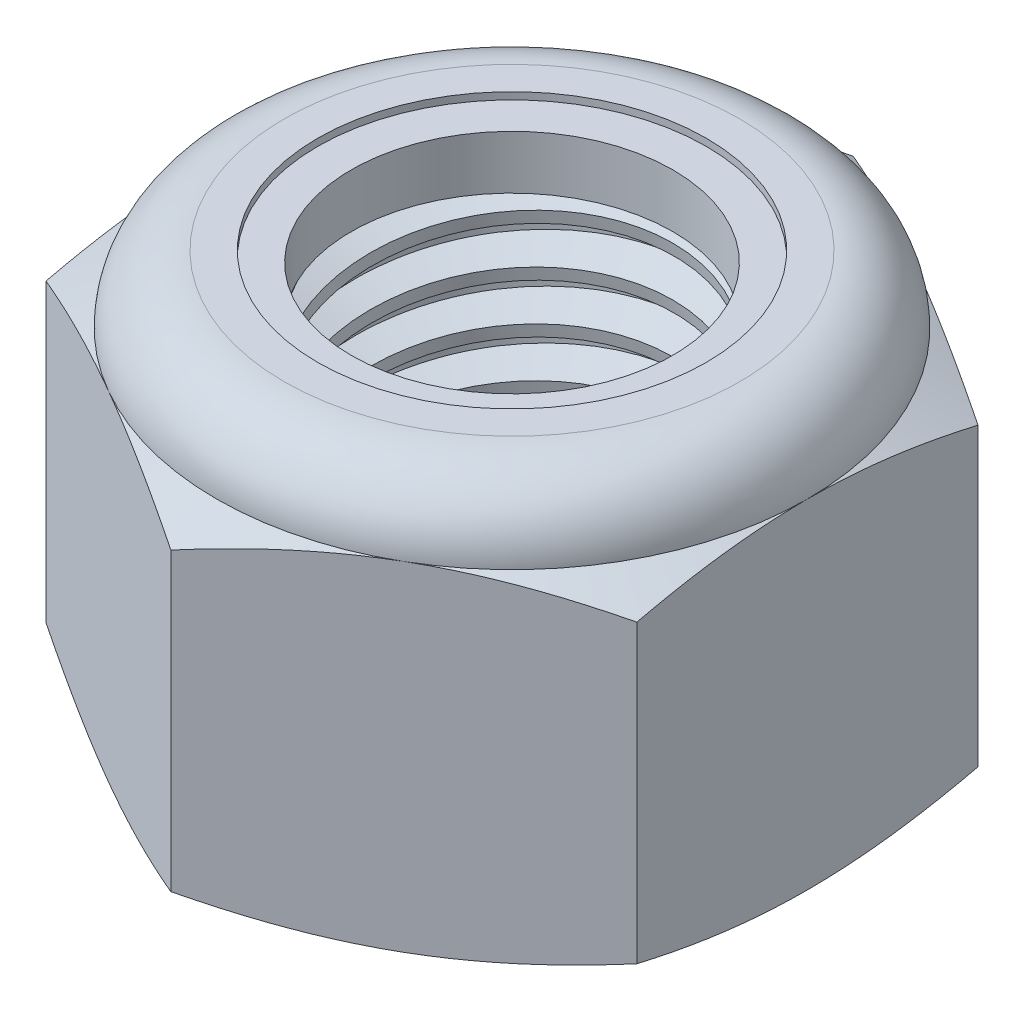
from build123d import *

# Parameters (mm, degrees)
EXTRUDE1_DEPTH       = 8.73125
SKETCH2_W            = 3.9624
SKETCH2_H            = 8.73125
LPATTERN1_COUNT      = 8
LPATTERN1_PITCH      = 1.058333333
LPATTERN1_COUNT_DIR2 = 2
LPATTERN1_PITCH_DIR2 = 1.058333333


with BuildPart() as part:
    # Sketch1 → Extrude1 (new body)
    with BuildSketch(Plane(origin=(0, 0, 0), x_dir=(1, 0, 0), z_dir=(0, 1, 0))):
        Polygon((0, 7.332348419), (-6.35, 3.666174209), (-6.35, -3.666174209), (0, -7.332348419), (6.35, -3.666174209), (6.35, 3.666174209), align=None)
    extrude(amount=EXTRUDE1_DEPTH)

    # Sketch4 → Cut-Revolve2 (revolve, cut)
    with BuildSketch(Plane(origin=(0, 0, 0), x_dir=(0, 0, -1), z_dir=(1, 0, 0))):
        Polygon((0, 8.73125), (3.9624, 8.73125), (3.4558921, 8.495061487), (3.4558921, 0.236188513), (3.9624, 0), (0, 0), align=None)
    revolve(axis=Axis((0, 8.73125, 0), (0, 1, 0)), mode=Mode.SUBTRACT)


with BuildPart() as body_2:
    # Sketch2 → Revolve1 (revolve)
    with BuildSketch(Plane(origin=(0, 0, 0), x_dir=(0, 0, -1), z_dir=(1, 0, 0))):
        with Locations((1.9812, 4.365625)):
            Rectangle(SKETCH2_W, SKETCH2_H)
    revolve(axis=Axis((0, -3.9624, 0), (0, 1, 0)))

    # Sketch3 → Cut-Revolve1 (revolve, cut)
    with BuildSketch(Plane(origin=(0, 0, 0), x_dir=(0, 0, -1), z_dir=(1, 0, 0))):
        Polygon((3.979911688, 8.600122482), (4.102493502, 7.682229859), (3.490915476, 7.934220821), (3.4558921, 8.196475856), align=None)
    cut_revolve1 = revolve(axis=Axis((0, 8.73125, 0.150876649), (0, -0.9912001327823777, -0.1323718126044843)), mode=Mode.SUBTRACT)

    # LPattern1: Cut-Revolve1 8 × 2
    with Locations(*[Vector(0, -1, 0) * (i * LPATTERN1_PITCH) + Vector(0, 1, 0) * (j * LPATTERN1_PITCH_DIR2) for i in range(LPATTERN1_COUNT) for j in range(LPATTERN1_COUNT_DIR2) if (i, j) != (0, 0)]):
        add(cut_revolve1, mode=Mode.SUBTRACT)


with BuildPart() as part_1:
    add(part.part)

    # Combine1: cut body 2
    add(body_2.part, mode=Mode.SUBTRACT)

    # Sketch5 → Cut-Revolve3 (revolve, cut)
    with BuildSketch(Plane(origin=(0, 0, 0), x_dir=(0, 0, -1), z_dir=(1, 0, 0))):
        with BuildLine():
            Line((0, 0), (6.35, 0))
            Line((6.35, 0), (7.332348419, 0.458076591))
            Line((7.332348419, 0.458076591), (7.332348419, 6.817965076))
            Line((7.332348419, 6.817965076), (6.35, 7.276041667))
            ThreePointArc((6.35, 7.276041667), (5.923779347, 8.305029347), (4.894791667, 8.73125))
            Line((4.894791667, 8.73125), (4.894791667, 10.00125))
            Line((4.894791667, 10.00125), (8.602348419, 10.00125))
            Line((8.602348419, 10.00125), (8.602348419, -1.27))
            Line((8.602348419, -1.27), (0, -1.27))
            Line((0, -1.27), (0, 0))
        make_face()
    revolve(axis=Axis((0, 0, 0), (0, 1, 0)), mode=Mode.SUBTRACT)

    # Sketch6 → Cut-Revolve4 (revolve, cut)
    with BuildSketch(Plane(origin=(0, 0, 0), x_dir=(0, 0, -1), z_dir=(1, 0, 0))):
        with BuildLine():
            Line((0, 7.276041667), (6.1976, 7.276041667))
            ThreePointArc((6.1976, 7.276041667), (5.816016274, 8.197266274), (4.894791667, 8.57885))
            Line((4.894791667, 8.57885), (4.175341883, 8.57885))
            Line((4.175341883, 8.57885), (4.175341883, 10.00125))
            Line((4.175341883, 10.00125), (0, 10.00125))
            Line((0, 10.00125), (0, 7.276041667))
        make_face()
    revolve(axis=Axis((0, 10.00125, 0), (0, 1, 0)), mode=Mode.SUBTRACT)


with BuildPart() as body_2_2:
    # Sketch7 → Revolve2 (revolve)
    with BuildSketch(Plane(origin=(0, 0, 0), x_dir=(0, 0, -1), z_dir=(1, 0, 0))):
        with BuildLine():
            Line((3.4558921, 7.352241667), (6.119030844, 7.352241667))
            ThreePointArc((6.119030844, 7.352241667), (5.734762038, 8.169919611), (4.894791667, 8.50265))
            Line((4.894791667, 8.50265), (3.4558921, 8.50265))
            Line((3.4558921, 8.50265), (3.4558921, 7.352241667))
        make_face()
    revolve(axis=Axis((0, 7.352241667, 0), (0, 1, 0)))


solid = Compound([part_1.part, body_2_2.part])
